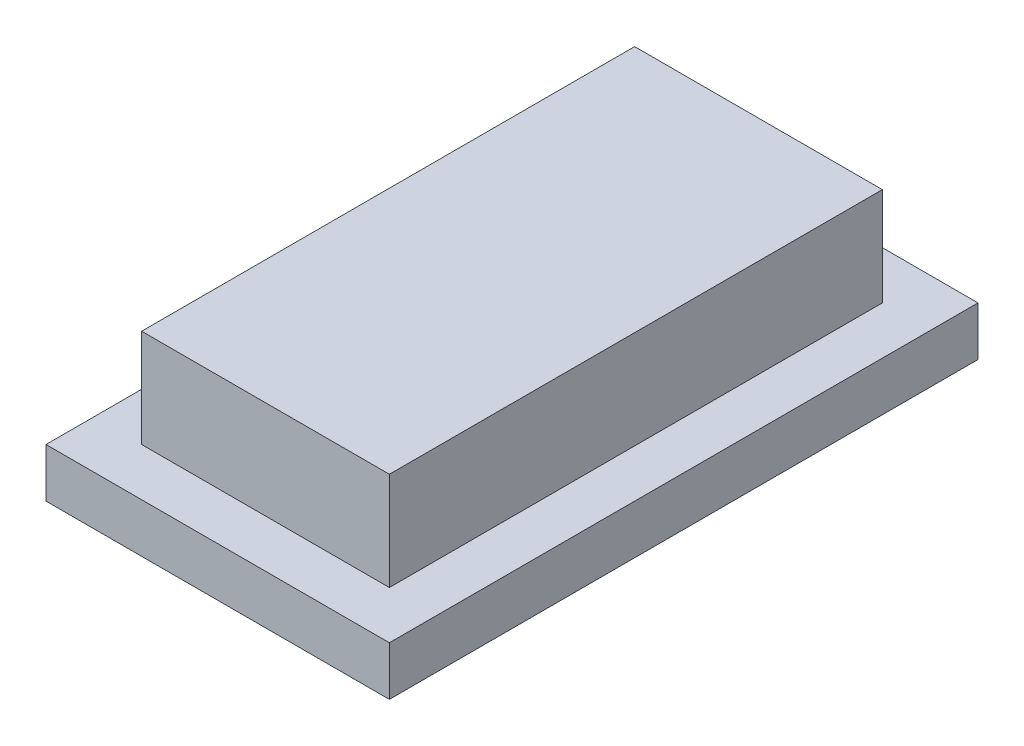
from build123d import *

# Parameters (mm, degrees)
SKETCH1_W           = 14
SKETCH1_H           = 24
BOSS_EXTRUDE1_DEPTH = 2
SKETCH2_W           = 10.1
SKETCH2_H           = 20.1
BOSS_EXTRUDE2_DEPTH = 4


with BuildPart() as part:
    # Sketch1 → Boss-Extrude1 (new body)
    with BuildSketch(Plane(origin=(0, 0, 0), x_dir=(1, 0, 0), z_dir=(0, 1, 0))):
        Rectangle(SKETCH1_W, SKETCH1_H)
    extrude(amount=BOSS_EXTRUDE1_DEPTH)

    # Sketch2 → Boss-Extrude2 (add)
    with BuildSketch(Plane(origin=(0, 2, 0), x_dir=(1, 0, 0), z_dir=(0, 1, 0))):
        Rectangle(SKETCH2_W, SKETCH2_H)
    extrude(amount=BOSS_EXTRUDE2_DEPTH)


solid = part.part
